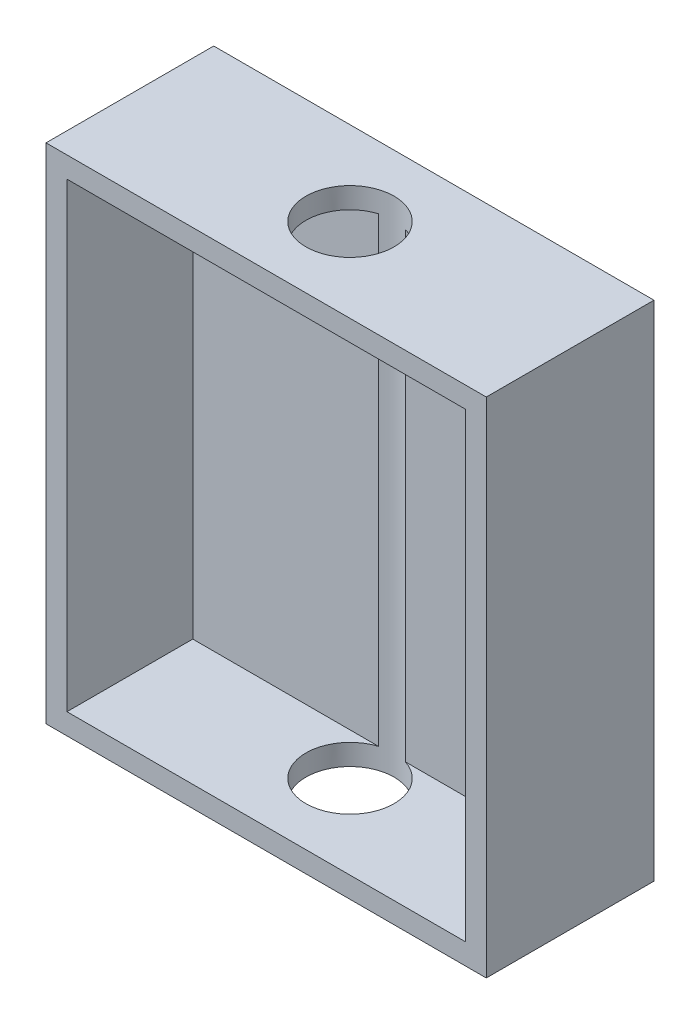
from build123d import *

# Parameters (mm, degrees)
SKETCH1_W           = 21
SKETCH1_H           = 24
SKETCH1_W_2         = 19
SKETCH1_H_2         = 22
BOSS_EXTRUDE1_DEPTH = 8
SKETCH2_W           = 19
SKETCH2_H           = 22
BOSS_EXTRUDE2_DEPTH = 2
SKETCH3_R           = 2.1
CUT_EXTRUDE1_DEPTH  = 30


with BuildPart() as part:
    # Sketch1 → Boss-Extrude1 (new body)
    with BuildSketch(Plane.XY):
        Rectangle(SKETCH1_W, SKETCH1_H)
        Rectangle(SKETCH1_W_2, SKETCH1_H_2, mode=Mode.SUBTRACT)
    extrude(amount=BOSS_EXTRUDE1_DEPTH)

    # Sketch2 → Boss-Extrude2 (add)
    with BuildSketch(Plane(origin=(0, 0, 0), x_dir=(-1, 0, 0), z_dir=(0, 0, -1))):
        Rectangle(SKETCH2_W, SKETCH2_H)
    extrude(amount=-BOSS_EXTRUDE2_DEPTH)

    # Sketch3 → Cut-Extrude1 (cut)
    with BuildSketch(Plane.XZ.offset(12)):
        with Locations((0, 4)):
            Circle(SKETCH3_R)
    extrude(amount=-CUT_EXTRUDE1_DEPTH, mode=Mode.SUBTRACT)


solid = part.part
